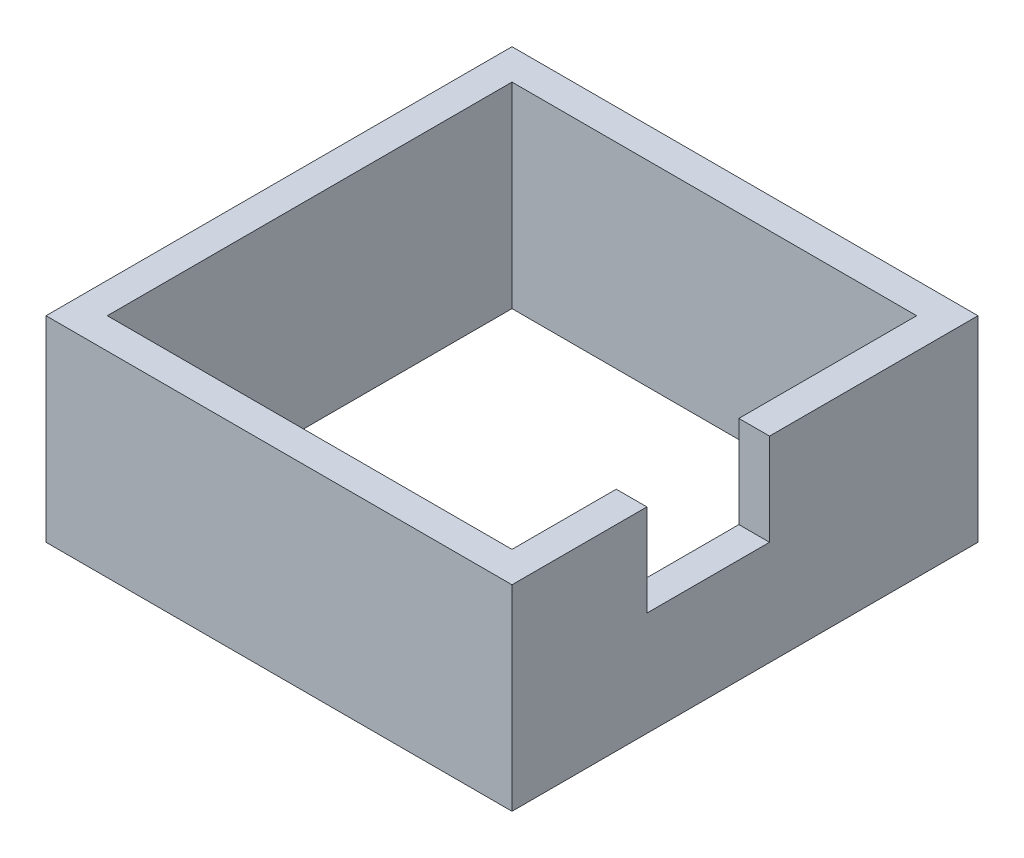
from build123d import *

# Parameters (mm, degrees)
SKETCH1_W           = 38
SKETCH1_H           = 38
SKETCH1_W_2         = 33
SKETCH1_H_2         = 33
BOSS_EXTRUDE1_DEPTH = 16
SKETCH2_W           = 10
SKETCH2_H           = 7.5
CUT_EXTRUDE1_DEPTH  = 2.5


with BuildPart() as part:
    # Sketch1 → Boss-Extrude1 (new body)
    with BuildSketch(Plane(origin=(0, 0, 0), x_dir=(1, 0, 0), z_dir=(0, 1, 0))):
        Rectangle(SKETCH1_W, SKETCH1_H)
        Rectangle(SKETCH1_W_2, SKETCH1_H_2, mode=Mode.SUBTRACT)
    extrude(amount=BOSS_EXTRUDE1_DEPTH)

    # Sketch2 → Cut-Extrude1 (cut)
    with BuildSketch(Plane(origin=(19, 0, 0), x_dir=(0, 0, -1), z_dir=(1, 0, 0))):
        with Locations((-3, 12.25)):
            Rectangle(SKETCH2_W, SKETCH2_H)
    extrude(amount=-CUT_EXTRUDE1_DEPTH, mode=Mode.SUBTRACT)


solid = part.part
